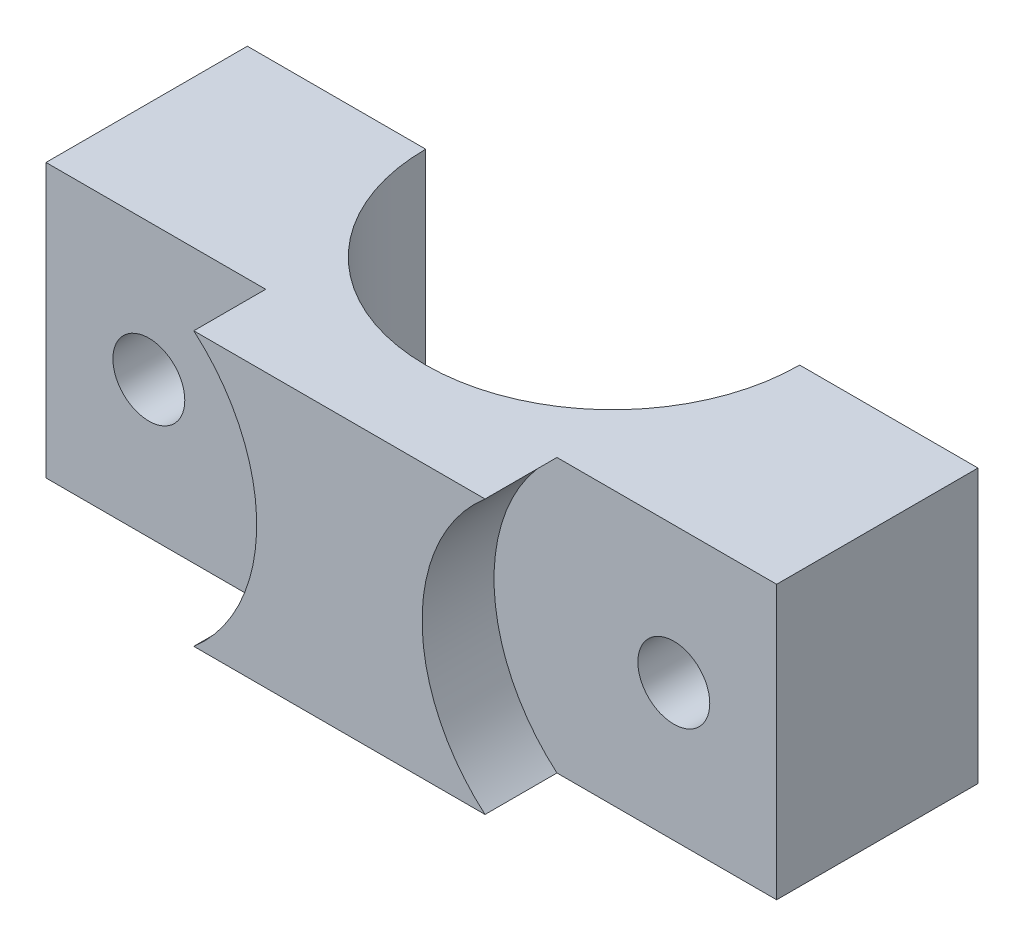
from build123d import *

# Parameters (mm, degrees)
SKETCH2_W               = 50.8
SKETCH2_H               = 19
BOSS_EXTRUDE1_DEPTH     = 19
SKETCH3_R               = 13
CUT_EXTRUDE1_DEPTH      = 20
SKETCH4_R               = 2.5
CUT_EXTRUDE2_DEPTH      = 5
SKETCH5_R               = 2.5
CUT_EXTRUDE3_DEPTH      = 1
CUT_EXTRUDE3_DEPTH_BACK = 20


with BuildPart() as part:
    # Sketch2 → Boss-Extrude1 (new body)
    with BuildSketch(Plane.XY):
        Rectangle(SKETCH2_W, SKETCH2_H)
    extrude(amount=BOSS_EXTRUDE1_DEPTH)

    # Sketch3 → Cut-Extrude1 (cut, through all)
    with BuildSketch(Plane.XZ.offset(9.5)):
        Circle(SKETCH3_R)
    extrude(amount=-CUT_EXTRUDE1_DEPTH, mode=Mode.SUBTRACT)

    # Sketch4 → Cut-Extrude2 (cut)
    with BuildSketch(Plane.XY.offset(19)):
        with BuildLine():
            ThreePointArc((-10.125961595, -9.5), (-6.896575846, -5.229699797), (-5.75, 0))
            ThreePointArc((-5.75, 0), (-6.896575846, 5.229699797), (-10.125961595, 9.5))
            Line((-10.125961595, 9.5), (-25.4, 9.5))
            Line((-25.4, 9.5), (-25.4, -9.5))
            Line((-25.4, -9.5), (-10.125961595, -9.5))
        make_face()
        with Locations((-18.25, 0)):
            Circle(SKETCH4_R, mode=Mode.SUBTRACT)
        with BuildLine():
            Line((25.4, 9.5), (10.125961595, 9.5))
            ThreePointArc((10.125961595, 9.5), (5.75, 0), (10.125961595, -9.5))
            Line((10.125961595, -9.5), (25.4, -9.5))
            Line((25.4, -9.5), (25.4, 9.5))
        make_face()
        with Locations((18.25, 0)):
            Circle(SKETCH4_R, mode=Mode.SUBTRACT)
    extrude(amount=-CUT_EXTRUDE2_DEPTH, mode=Mode.SUBTRACT)

    # Sketch5 → Cut-Extrude3 (cut, two sides)
    with BuildSketch(Plane.XY.offset(19)) as cut_extrude3_sk:
        with Locations((18.25, 0)):
            Circle(SKETCH5_R)
        with Locations((-18.25, 0)):
            Circle(SKETCH5_R)
    extrude(amount=CUT_EXTRUDE3_DEPTH, mode=Mode.SUBTRACT)
    extrude(cut_extrude3_sk.sketch, amount=-CUT_EXTRUDE3_DEPTH_BACK, mode=Mode.SUBTRACT)


solid = part.part
